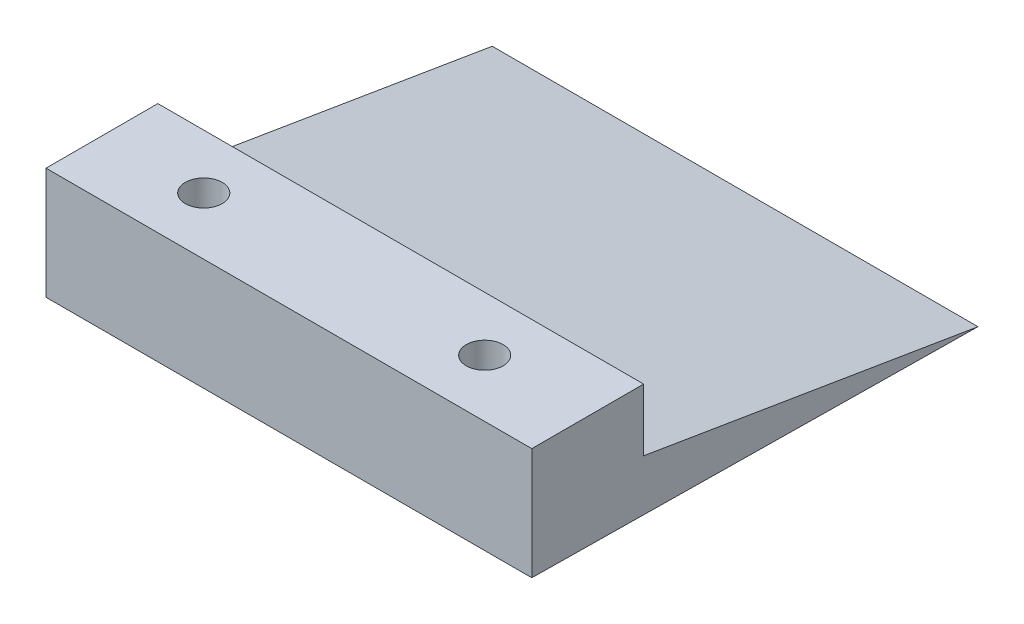
from build123d import *

# Parameters (mm, degrees)
BOSS_EXTRUDE1_DEPTH                            = 21.5
SKETCH4_R                                      = 0.685
CUT_EXTRUDE1_DEPTH                             = 11.401915701
CBORE_FOR_4_SOCKET_HEAD_CAP_SCREW1_D           = 3.2639
CBORE_FOR_4_SOCKET_HEAD_CAP_SCREW1_CBORE_D     = 5.55752
CBORE_FOR_4_SOCKET_HEAD_CAP_SCREW1_CBORE_DEPTH = 6.844792


with BuildPart() as part:
    # Sketch2 → Boss-Extrude1 (new body, symmetric)
    with BuildSketch(Plane(origin=(0, 0, 0), x_dir=(0, 0, -1), z_dir=(1, 0, 0))):
        Polygon((0, 0), (29.596811018, -4.901915701), (-9.9, -4.4), (-9.9, 5.5), (0, 5.5), align=None)
    extrude(amount=BOSS_EXTRUDE1_DEPTH, both=True)

    # Sketch4 → Cut-Extrude1 (cut, through all)
    with BuildSketch(Plane(origin=(0, 5.5, 0), x_dir=(1, 0, 0), z_dir=(0, 1, 0))):
        with Locations((-12.615, -4.95)):
            Circle(SKETCH4_R)
        with Locations((12.255, -4.95)):
            Circle(SKETCH4_R)
    extrude(amount=-CUT_EXTRUDE1_DEPTH, mode=Mode.SUBTRACT)

    # CBORE for #4 Socket Head Cap Screw1 (through all)
    with Locations(Plane(origin=(0, -4.525076009, 0.057503546), x_dir=(-1, 0, 0), z_dir=(0, -0.999919266, 0.012706727))):
        with Locations((12.615, -4.892891475), (-12.255, -4.892891475)):
            CounterBoreHole(CBORE_FOR_4_SOCKET_HEAD_CAP_SCREW1_D / 2, CBORE_FOR_4_SOCKET_HEAD_CAP_SCREW1_CBORE_D / 2, CBORE_FOR_4_SOCKET_HEAD_CAP_SCREW1_CBORE_DEPTH)


solid = part.part
